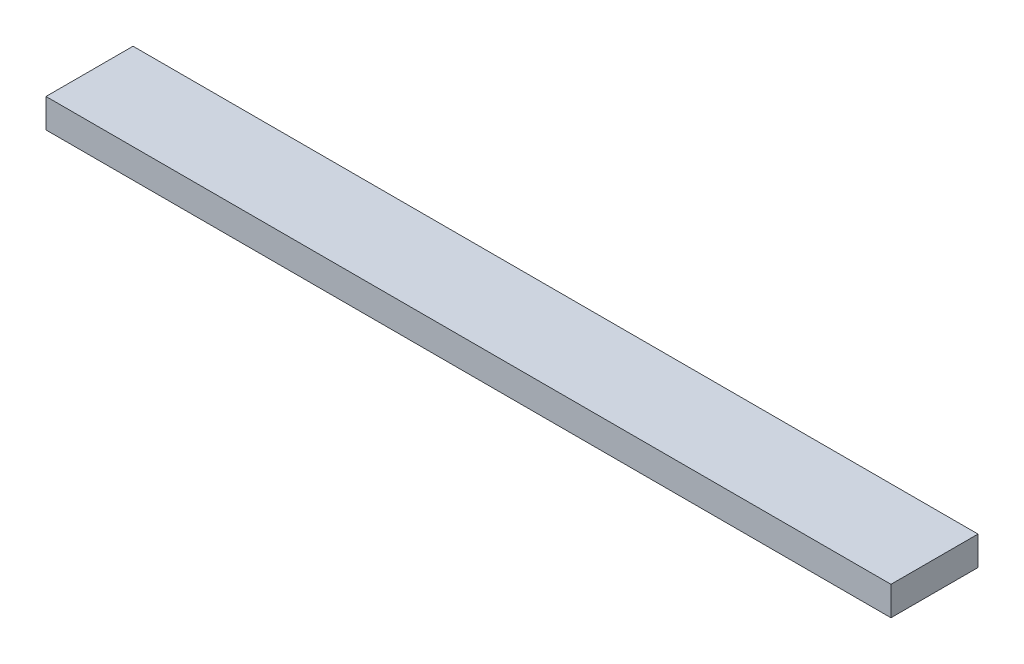
from build123d import *

# Parameters (mm, degrees)
SKETCH_1_W      = 582.508294322
SKETCH_1_H      = 60
EXTRUDE_1_DEPTH = 20


with BuildPart() as part:
    # Эскиз1 → Бобышка-Вытянуть1 (new body)
    with BuildSketch(Plane(origin=(0, 0, 0), x_dir=(1, 0, 0), z_dir=(0, 1, 0))):
        Rectangle(SKETCH_1_W, SKETCH_1_H)
    extrude(amount=EXTRUDE_1_DEPTH)


solid = part.part
